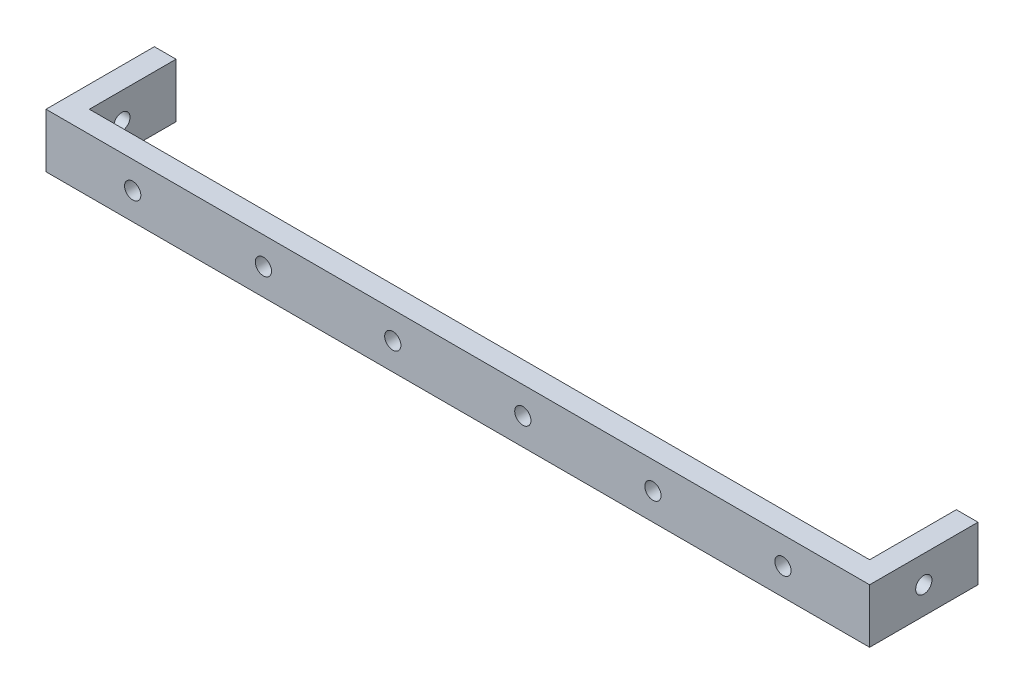
from build123d import *

# Parameters (mm, degrees)
SKETCH1_W           = 72
SKETCH1_H           = 5
BOSS_EXTRUDE1_DEPTH = 2
SKETCH3_R           = 0.75
CUT_EXTRUDE2_DEPTH  = 2
SKETCH4_W           = 10
SKETCH4_H           = 5
BOSS_EXTRUDE2_DEPTH = 2
SKETCH5_R           = 0.75
CUT_EXTRUDE4_DEPTH  = 2
SKETCH6_W           = 10
SKETCH6_H           = 5
BOSS_EXTRUDE3_DEPTH = 2
SKETCH7_R           = 0.75
CUT_EXTRUDE5_DEPTH  = 2


with BuildPart() as part:
    # Sketch1 → Boss-Extrude1 (new body)
    with BuildSketch(Plane.XY):
        with Locations((36, 2.5)):
            Rectangle(SKETCH1_W, SKETCH1_H)
    extrude(amount=BOSS_EXTRUDE1_DEPTH)

    # Sketch3 → Cut-Extrude2 (cut)
    with BuildSketch(Plane.XY):
        with Locations((42, 2.5)):
            Circle(SKETCH3_R)
        with Locations((54, 2.5)):
            Circle(SKETCH3_R)
        with Locations((66, 2.5)):
            Circle(SKETCH3_R)
        with Locations((30, 2.5)):
            Circle(SKETCH3_R)
        with Locations((18.06024044, 2.463599586)):
            Circle(SKETCH3_R)
        with Locations((6, 2.5)):
            Circle(SKETCH3_R)
    extrude(amount=CUT_EXTRUDE2_DEPTH, mode=Mode.SUBTRACT)

    # Sketch4 → Boss-Extrude2 (add)
    with BuildSketch(Plane(origin=(72, 0, 0), x_dir=(0, 0, -1), z_dir=(1, 0, 0))):
        with Locations((3, 2.5)):
            Rectangle(SKETCH4_W, SKETCH4_H)
    extrude(amount=BOSS_EXTRUDE2_DEPTH)

    # Sketch5 → Cut-Extrude4 (cut)
    with BuildSketch(Plane(origin=(72, 0, 0), x_dir=(0, 0, -1), z_dir=(1, 0, 0))):
        with Locations((3, 2.5)):
            Circle(SKETCH5_R)
    extrude(amount=CUT_EXTRUDE4_DEPTH, mode=Mode.SUBTRACT)

    # Sketch6 → Boss-Extrude3 (add)
    with BuildSketch(Plane.ZY):
        with Locations((-3, 2.5)):
            Rectangle(SKETCH6_W, SKETCH6_H)
    extrude(amount=BOSS_EXTRUDE3_DEPTH)

    # Sketch7 → Cut-Extrude5 (cut)
    with BuildSketch(Plane.ZY):
        with Locations((-3, 2.5)):
            Circle(SKETCH7_R)
    extrude(amount=CUT_EXTRUDE5_DEPTH, mode=Mode.SUBTRACT)


solid = part.part
